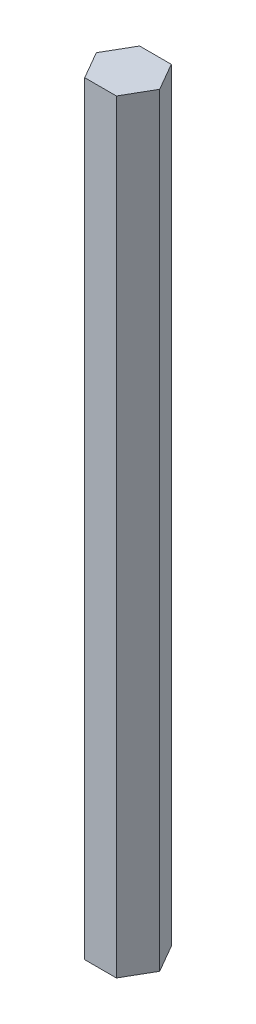
from build123d import *

# Parameters (mm, degrees)
BOSS_EXTRUDE1_DEPTH = 192.89


with BuildPart() as part:
    # Sketch1 → Boss-Extrude1 (new body)
    with BuildSketch(Plane(origin=(0, 0, 0), x_dir=(1, 0, 0), z_dir=(0, 1, 0))):
        Polygon((7.977059052, 1.579344013), (3.977059052, 8.507547244), (-4.022940948, 8.507547244), (-8.022940948, 1.579344013), (-4.022940948, -5.348859217), (3.977059052, -5.348859217), align=None)
    extrude(amount=BOSS_EXTRUDE1_DEPTH)


solid = part.part
